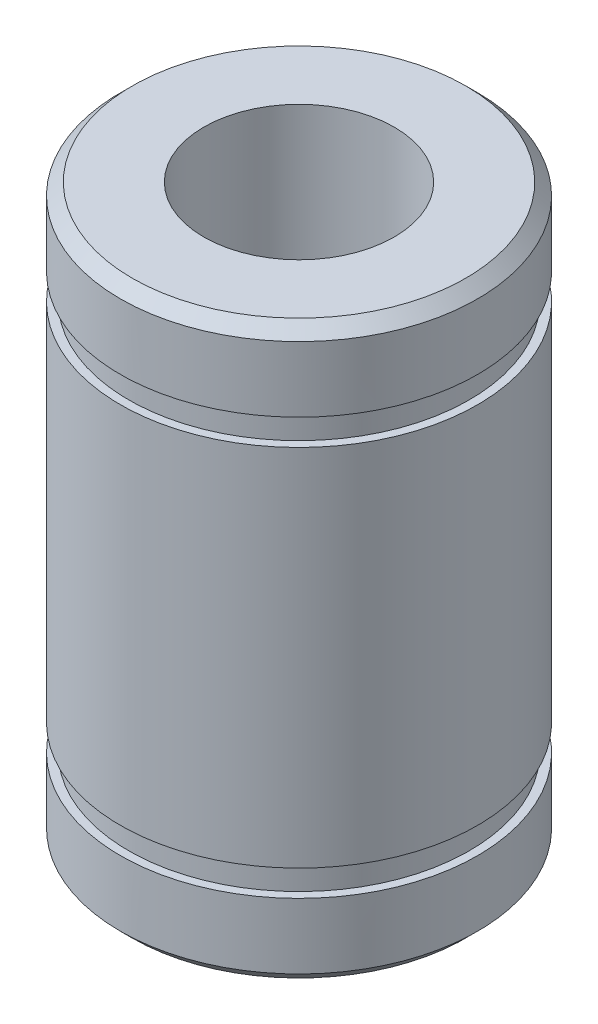
from build123d import *

# Parameters (mm, degrees)
CHAMFER1_SIZE = 0.5


with BuildPart() as part:
    # Sketch1 → Revolve1 (revolve)
    with BuildSketch(Plane.XY):
        Polygon((4, 0), (4, 12), (7.5, 12), (7.5, 8.75), (7.15, 8.75), (7.15, 7.65), (7.5, 7.65), (7.5, 0), align=None)
    revolve(axis=Axis((0, 0, 0), (0, 1, 0)))

    # Chamfer1
    chamfer1_edges = [part.edges().sort_by_distance(p)[0] for p in [
        (-7.5, 12, 0),
    ]]
    chamfer(chamfer1_edges, length=CHAMFER1_SIZE)

    # Mirror1: part across plane


with BuildPart() as part_1:
    add(part.part)
    add(part.part.mirror(Plane(origin=(7.5, 0, 0), x_dir=(0, 0, 1), z_dir=(0, -1, 0))))


solid = part_1.part
